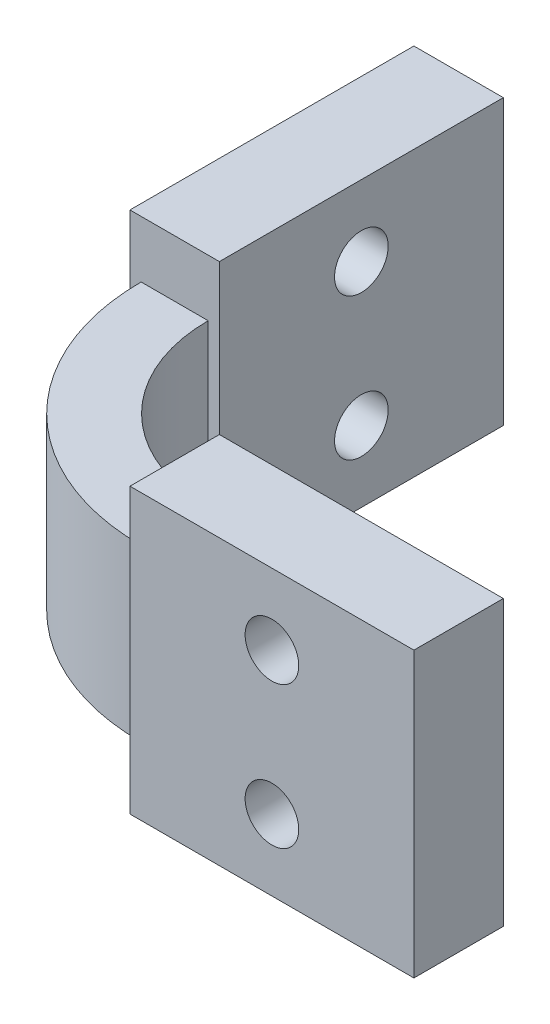
from build123d import *

# Parameters (mm, degrees)
BOSS_EXTRUDE1_DEPTH  = 3.81
SKETCH3_W            = 12.7
SKETCH3_H            = 4
SKETCH3_W_2          = 4
SKETCH3_H_2          = 12.7
BOSS_EXTRUDE2_DEPTH  = 2.54
M2_CLEARANCE_HOLE1_D = 2.4
M2_CLEARANCE_HOLE2_D = 2.4


with BuildPart() as part:
    # Sketch2 → Boss-Extrude1 (new body, symmetric)
    with BuildSketch(Plane(origin=(0, 0, 0), x_dir=(1, 0, 0), z_dir=(0, 1, 0))):
        with BuildLine():
            Line((-3.746, 20.86), (0.254, 20.86))
            Line((0.254, 20.86), (0.254, 8.16))
            Line((0.254, 8.16), (-0.246, 8.16))
            ThreePointArc((-0.246, 8.16), (1.862831175, 3.068831175), (6.954, 0.96))
            Line((6.954, 0.96), (6.954, 1.46))
            Line((6.954, 1.46), (19.654, 1.46))
            Line((19.654, 1.46), (19.654, -2.54))
            Line((19.654, -2.54), (6.954, -2.54))
            Line((6.954, -2.54), (6.954, -2.04))
            ThreePointArc((6.954, -2.04), (-0.258489168, 0.947510832), (-3.246, 8.16))
            Line((-3.246, 8.16), (-3.746, 8.16))
            Line((-3.746, 8.16), (-3.746, 20.86))
        make_face()
    extrude(amount=BOSS_EXTRUDE1_DEPTH, both=True)

    # Sketch3 → Boss-Extrude2 (add)
    with BuildSketch(Plane(origin=(0, 3.81, 0), x_dir=(1, 0, 0), z_dir=(0, 1, 0))):
        with Locations((13.304, -0.54)):
            Rectangle(SKETCH3_W, SKETCH3_H)
        with Locations((-1.746, 14.51)):
            Rectangle(SKETCH3_W_2, SKETCH3_H_2)
    boss_extrude2 = extrude(amount=BOSS_EXTRUDE2_DEPTH)

    # Mirror1: Boss-Extrude2 across plane
    add(boss_extrude2.mirror(Plane.ZX))

    # M2 Clearance Hole1 (through all)
    with Locations(Plane(origin=(0.254, 0, 0), x_dir=(0, 0, -1), z_dir=(1, 0, 0))):
        with Locations((14.51, 3.175), (14.51, -3.175)):
            Hole(M2_CLEARANCE_HOLE1_D / 2)

    # M2 Clearance Hole2 (through all)
    with Locations(Plane(origin=(0, 0, -1.46), x_dir=(-1, 0, 0), z_dir=(0, 0, -1))):
        with Locations((-13.304, 3.175), (-13.304, -3.175)):
            Hole(M2_CLEARANCE_HOLE2_D / 2)


solid = part.part
